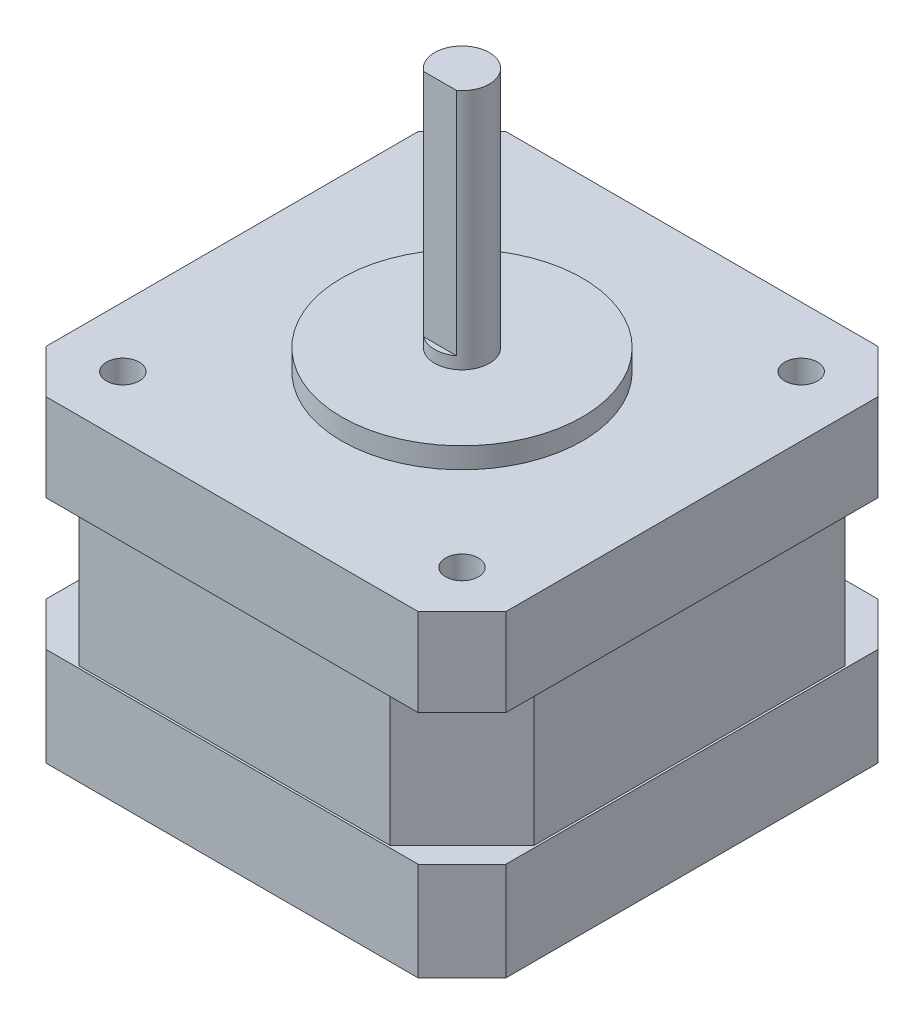
from build123d import *

# Parameters (mm, degrees)
SKETCH_1_W                = 8
SKETCH_1_H                = 42
EXTRUDE_1_DEPTH           = 0.2
EXTRUDE_2_DEPTH           = 41.6
SKETCH_3_W                = 42
SKETCH_3_H                = 8
EXTRUDE_3_DEPTH           = 0.2
SKETCH_4_W                = 42
SKETCH_4_H                = 42
EXTRUDE_4_DEPTH           = 9
SKETCH_5_R                = 11
EXTRUDE_5_DEPTH           = 1.9
SKETCH_6_R                = 2.5
EXTRUDE_6_DEPTH           = 22.1
CUT_EXTRUDE_1_DEPTH       = 21
SKETCH_8_W                = 2.5
SKETCH_8_H                = 8
HOLE_WIZARD_5_0_5_1_D     = 5
HOLE_WIZARD_5_0_5_1_DEPTH = 5
HOLE_WIZARD_3_0_3_1_D     = 3
HOLE_WIZARD_3_0_3_1_DEPTH = 4
CHAMFER_1_SIZE            = 6.6
CHAMFER_2_SIZE            = 4


with BuildPart() as part:
    # 스케치1 → 보스-돌출1 (new body)
    with BuildSketch(Plane(origin=(-21, 0, 0), x_dir=(0, -1, 0), z_dir=(-1, 0, 0))):
        with Locations((4, 0)):
            Rectangle(SKETCH_1_W, SKETCH_1_H)
    extrude(amount=-EXTRUDE_1_DEPTH)

    # 스케치2 → 보스-돌출2 (add)
    with BuildSketch(Plane(origin=(-20.8, 0, 0), x_dir=(0, 0, -1), z_dir=(1, 0, 0))):
        Polygon((20.8, -8), (20.8, -20), (-20.8, -20), (-20.8, -8), (-21, -8), (-21, 0), (21, 0), (21, -8), align=None)
    extrude(amount=EXTRUDE_2_DEPTH)

    # 스케치3 → 보스-돌출3 (add)
    with BuildSketch(Plane(origin=(20.8, 0, 0), x_dir=(0, 0, -1), z_dir=(1, 0, 0))):
        with Locations((0, -4)):
            Rectangle(SKETCH_3_W, SKETCH_3_H)
    extrude(amount=EXTRUDE_3_DEPTH)

    # 스케치4 → 보스-돌출4 (add)
    with BuildSketch(Plane(origin=(0, -20, 0), x_dir=(1, 0, 0), z_dir=(0, 1, 0))):
        Rectangle(SKETCH_4_W, SKETCH_4_H)
    extrude(amount=-EXTRUDE_4_DEPTH)

    # 스케치5 → 보스-돌출5 (add)
    with BuildSketch(Plane(origin=(0, 0, 0), x_dir=(-1, 0, 0), z_dir=(0, 1, 0))):
        Circle(SKETCH_5_R)
    extrude(amount=EXTRUDE_5_DEPTH)

    # 스케치6 → 보스-돌출6 (add)
    with BuildSketch(Plane(origin=(0, 1.9, 0), x_dir=(-1, 0, 0), z_dir=(0, 1, 0))):
        Circle(SKETCH_6_R)
    extrude(amount=EXTRUDE_6_DEPTH)

    # 스케치7 → 컷-돌출1 (cut)
    with BuildSketch(Plane(origin=(0, 24, 0), x_dir=(-1, 0, 0), z_dir=(0, 1, 0))):
        with BuildLine():
            Line((-1.5, 2), (1.5, 2))
            ThreePointArc((1.5, 2), (0, 2.5), (-1.5, 2))
        make_face()
    extrude(amount=-CUT_EXTRUDE_1_DEPTH, mode=Mode.SUBTRACT)

    # 스케치8 → 컷-회전1 (revolve, cut)
    with BuildSketch(Plane.XY):
        with Locations((1.25, -4)):
            Rectangle(SKETCH_8_W, SKETCH_8_H)
    revolve(axis=Axis((0, 0, 0), (0, -1, 0)), mode=Mode.SUBTRACT)

    # Ø5.0 (5) 지름 구멍1
    with Locations(Plane(origin=(0, -29, 0), x_dir=(-1, 0, 0), z_dir=(0, -1, 0))):
        with Locations((0, 0)):
            Hole(HOLE_WIZARD_5_0_5_1_D / 2, depth=HOLE_WIZARD_5_0_5_1_DEPTH)

    # Ø3.0 (3) 지름 구멍1
    with Locations(Plane(origin=(0, 0, 0), x_dir=(1, 0, 0), z_dir=(0, 1, 0))):
        with Locations((-15.5, 15.5), (15.5, -15.5), (15.5, 15.5), (-15.5, -15.5)):
            Hole(HOLE_WIZARD_3_0_3_1_D / 2, depth=HOLE_WIZARD_3_0_3_1_DEPTH)

    # 모따기1
    chamfer_1_edges = [part.edges().sort_by_distance(p)[0] for p in [
        (-20.8, -14, 20.8),
        (-20.8, -14, -20.8),
        (20.8, -14, 20.8),
        (20.8, -14, -20.8),
    ]]
    chamfer(chamfer_1_edges, length=CHAMFER_1_SIZE)

    # 모따기2
    chamfer_2_edges = [part.edges().sort_by_distance(p)[0] for p in [
        (21, -4, -21),
        (21, -4, 21),
        (-21, -24.5, 21),
        (-21, -24.5, -21),
        (21, -24.5, -21),
        (21, -24.5, 21),
        (-21, -4, 21),
        (-21, -4, -21),
    ]]
    chamfer(chamfer_2_edges, length=CHAMFER_2_SIZE)


solid = part.part
